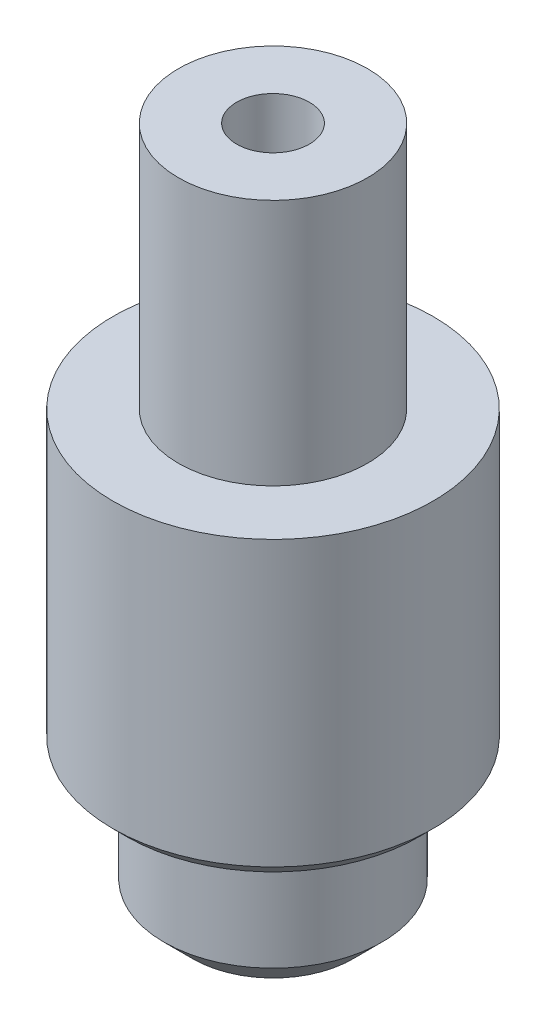
from build123d import *

# Parameters (mm, degrees)
CHAMFER1_SIZE = 2
CHAMFER2_SIZE = 1


with BuildPart() as part:
    # Sketch1 → Revolve1 (revolve)
    with BuildSketch(Plane.XY):
        Polygon((-7.5, -20.5), (-7.5, -30), (-2, -30), (-2, -20.5), (-2.5, -20.5), (-2.5, 17), (-6.5, 17), (-6.5, 0), (-11, 0), (-11, -20.5), align=None)
    revolve(axis=Axis((0, -30, 0), (0, 1, 0)))

    # Chamfer1
    chamfer1_edges = [part.edges().sort_by_distance(p)[0] for p in [
        (7.5, -30, 0),
    ]]
    chamfer(chamfer1_edges, length=CHAMFER1_SIZE)

    # Chamfer2
    chamfer2_edges = [part.edges().sort_by_distance(p)[0] for p in [
        (11, -20.5, 0),
    ]]
    chamfer(chamfer2_edges, length=CHAMFER2_SIZE)


solid = part.part
